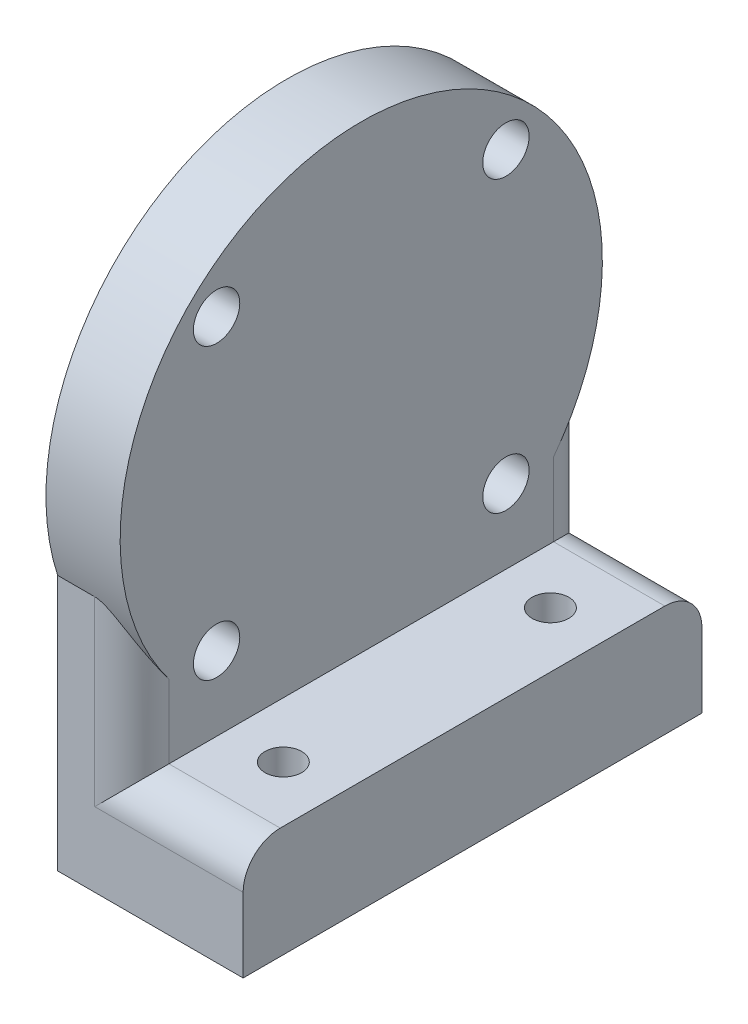
from build123d import *

# Parameters (mm, degrees)
SKETCH1_R           = 32.5
BOSS_EXTRUDE1_DEPTH = 10
SKETCH2_R           = 3.125
CUT_EXTRUDE1_DEPTH  = 11
BOSS_EXTRUDE2_DEPTH = 10
SKETCH4_W           = 61.846584384
SKETCH4_H           = 15
BOSS_EXTRUDE3_DEPTH = 15
SKETCH5_R           = 2.475
CUT_EXTRUDE2_DEPTH  = 16
FILLET1_R           = 5


with BuildPart() as part:
    # Sketch1 → Boss-Extrude1 (new body)
    with BuildSketch(Plane(origin=(0, 0, 0), x_dir=(0, 0, -1), z_dir=(1, 0, 0))):
        Circle(SKETCH1_R)
    extrude(amount=BOSS_EXTRUDE1_DEPTH)

    # Sketch2 → Cut-Extrude1 (cut, through all)
    with BuildSketch(Plane(origin=(10, 0, 0), x_dir=(0, 0, -1), z_dir=(1, 0, 0))):
        with Locations((-19.502005025, -19.502005025)):
            Circle(SKETCH2_R)
        with Locations((-19.502005025, 19.502005025)):
            Circle(SKETCH2_R)
        with Locations((19.502005025, 19.502005025)):
            Circle(SKETCH2_R)
        with Locations((19.502005025, -19.502005025)):
            Circle(SKETCH2_R)
    extrude(amount=-CUT_EXTRUDE1_DEPTH, mode=Mode.SUBTRACT)



with BuildPart() as body_2:
    # Sketch3 → Boss-Extrude2 (new body)
    with BuildSketch(Plane.ZY):
        with BuildLine():
            Line((-30.923292192, -10), (-30.923292192, -44.5))
            Line((-30.923292192, -44.5), (30.923292192, -44.5))
            Line((30.923292192, -44.5), (30.923292192, -10))
            ThreePointArc((30.923292192, -10), (0, -32.5), (-30.923292192, -10))
        make_face()
    extrude(amount=-BOSS_EXTRUDE2_DEPTH)


with BuildPart() as part_1:
    add(part.part)

    add(body_2.part)  # Boss-Extrude3 merges body 2
    # Sketch4 → Boss-Extrude3 (add)
    with BuildSketch(Plane(origin=(10, 0, 0), x_dir=(0, 0, -1), z_dir=(1, 0, 0))):
        with Locations((0, -37)):
            Rectangle(SKETCH4_W, SKETCH4_H)
    extrude(amount=BOSS_EXTRUDE3_DEPTH)

    # Sketch5 → Cut-Extrude2 (cut, through all)
    with BuildSketch(Plane(origin=(0, -29.5, 0), x_dir=(1, 0, 0), z_dir=(0, 1, 0))):
        with Locations((17.5, -18)):
            Circle(SKETCH5_R)
        with Locations((17.5, 18)):
            Circle(SKETCH5_R)
    extrude(amount=-CUT_EXTRUDE2_DEPTH, mode=Mode.SUBTRACT)

    # Fillet1
    fillet1_edges = [part_1.edges().sort_by_distance(p)[0] for p in [
        (17.5, -29.5, 30.923292192),
        (17.5, -29.5, -30.923292192),
        (10, -19.75, -30.923292192),
        (10, -19.75, 30.923292192),
    ]]
    fillet(fillet1_edges, radius=FILLET1_R)


solid = part_1.part
